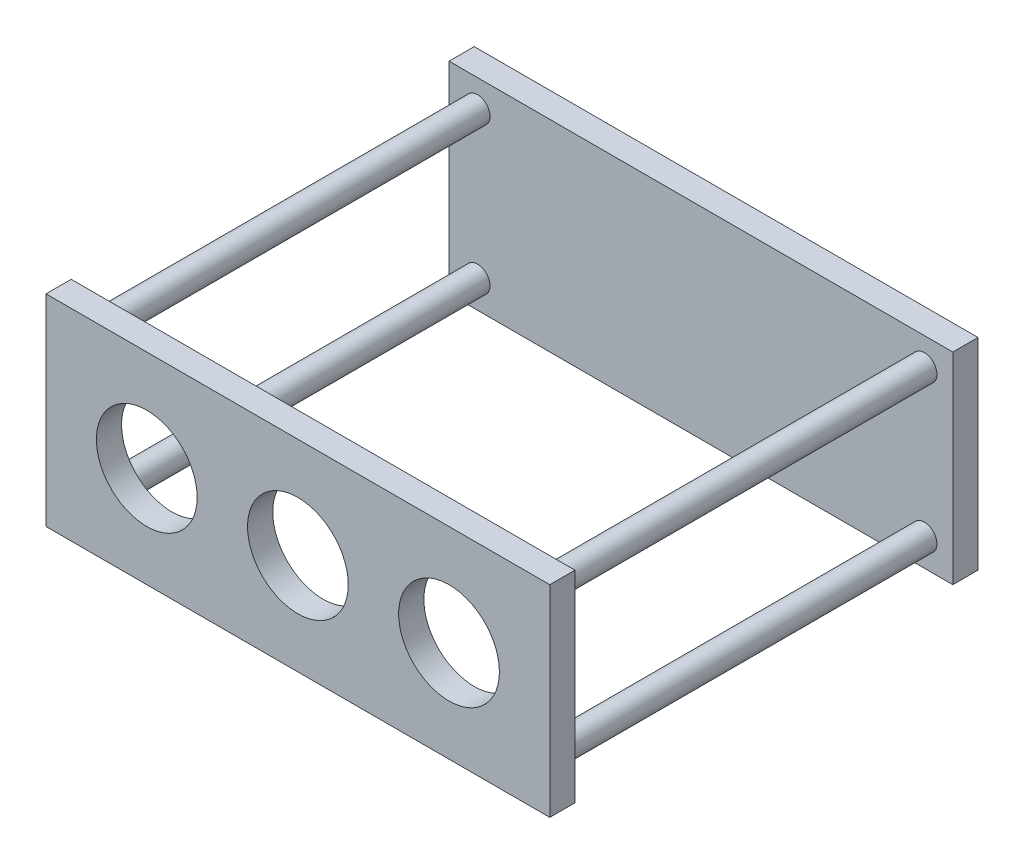
from build123d import *

# Parameters (mm, degrees)
SKETCH1_W           = 200
SKETCH1_H           = 80
BOSS_EXTRUDE1_DEPTH = 10
SKETCH2_R           = 5
BOSS_EXTRUDE2_DEPTH = 160
SKETCH3_W           = 200
SKETCH3_H           = 80
BOSS_EXTRUDE3_DEPTH = 10
SKETCH7_R           = 20
CUT_EXTRUDE1_DEPTH  = 10


with BuildPart() as part:
    # Sketch1 → Boss-Extrude1 (new body)
    with BuildSketch(Plane.XY):
        Rectangle(SKETCH1_W, SKETCH1_H)
    extrude(amount=BOSS_EXTRUDE1_DEPTH)

    # Sketch2 → Boss-Extrude2 (add)
    with BuildSketch(Plane.XY):
        with Locations((-88.708175614, 29.131974832)):
            Circle(SKETCH2_R)
        with Locations((88.708175614, 29.131974832)):
            Circle(SKETCH2_R)
        with Locations((88.708175614, -29.131974832)):
            Circle(SKETCH2_R)
        with Locations((-88.708175614, -29.131974832)):
            Circle(SKETCH2_R)
    extrude(amount=BOSS_EXTRUDE2_DEPTH)

    # Sketch3 → Boss-Extrude3 (add)
    with BuildSketch(Plane.XY.offset(160)):
        Rectangle(SKETCH3_W, SKETCH3_H)
    extrude(amount=BOSS_EXTRUDE3_DEPTH)

    # Sketch7 → Cut-Extrude1 (cut)
    with BuildSketch(Plane.XY.offset(170)):
        Circle(SKETCH7_R)
        with Locations((-60, 0)):
            Circle(SKETCH7_R)
        with Locations((60, 0)):
            Circle(SKETCH7_R)
    extrude(amount=-CUT_EXTRUDE1_DEPTH, mode=Mode.SUBTRACT)


solid = part.part
